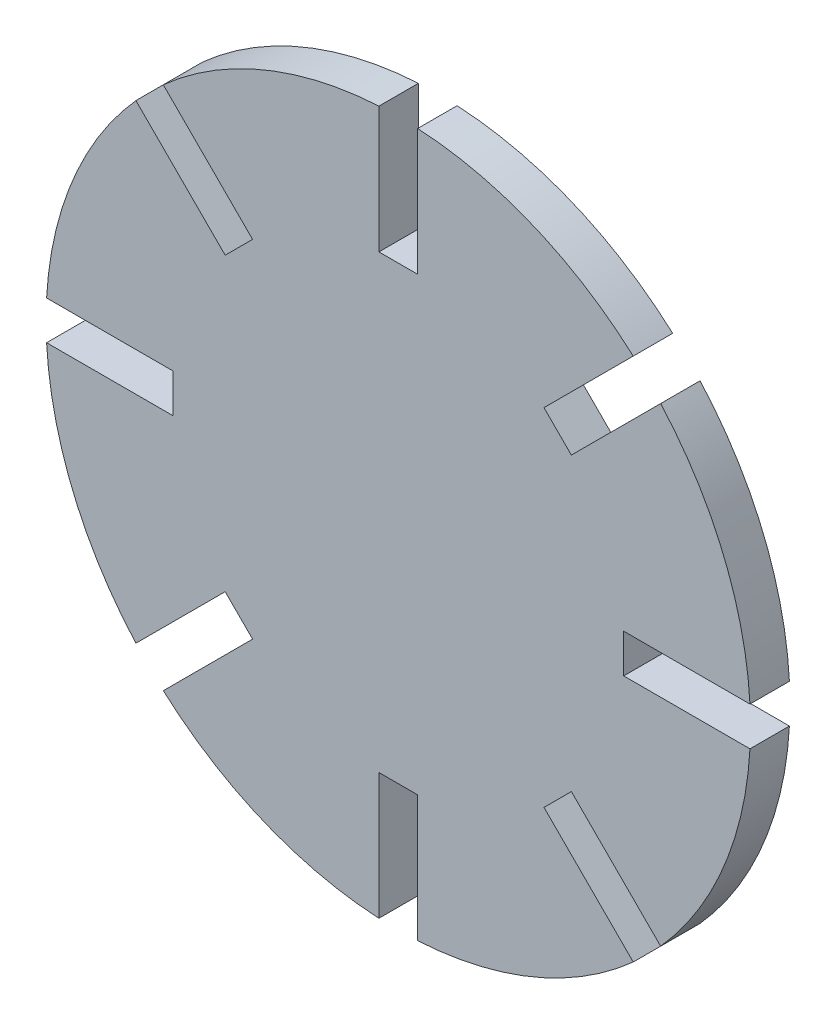
from build123d import *

# Parameters (mm, degrees)
CROQUIS1_R              = 25
SALIENTE_EXTRUIR1_DEPTH = 2.8
CROQUIS2_W              = 2.75
CROQUIS2_H              = 18
CORTAR_EXTRUIR1_DEPTH   = 3.8
MATRIZC1_COUNT          = 8


with BuildPart() as part:
    # Croquis1 → Saliente-Extruir1 (new body)
    with BuildSketch(Plane.XY):
        Circle(CROQUIS1_R)
    extrude(amount=SALIENTE_EXTRUIR1_DEPTH)

    # Croquis2 → Cortar-Extruir1 (cut, through all)
    with BuildSketch(Plane.XY):
        with Locations((0, 25)):
            Rectangle(CROQUIS2_W, CROQUIS2_H)
    cortar_extruir1 = extrude(amount=CORTAR_EXTRUIR1_DEPTH, mode=Mode.SUBTRACT)

    # MatrizC1: Cortar-Extruir1 ×8 about axis
    matrizc1_axis = Axis((0, 0, 0), (0, 0, 1))
    for i in range(1, MATRIZC1_COUNT):
        add(cortar_extruir1.rotate(matrizc1_axis, i * 360 / MATRIZC1_COUNT), mode=Mode.SUBTRACT)


solid = part.part
